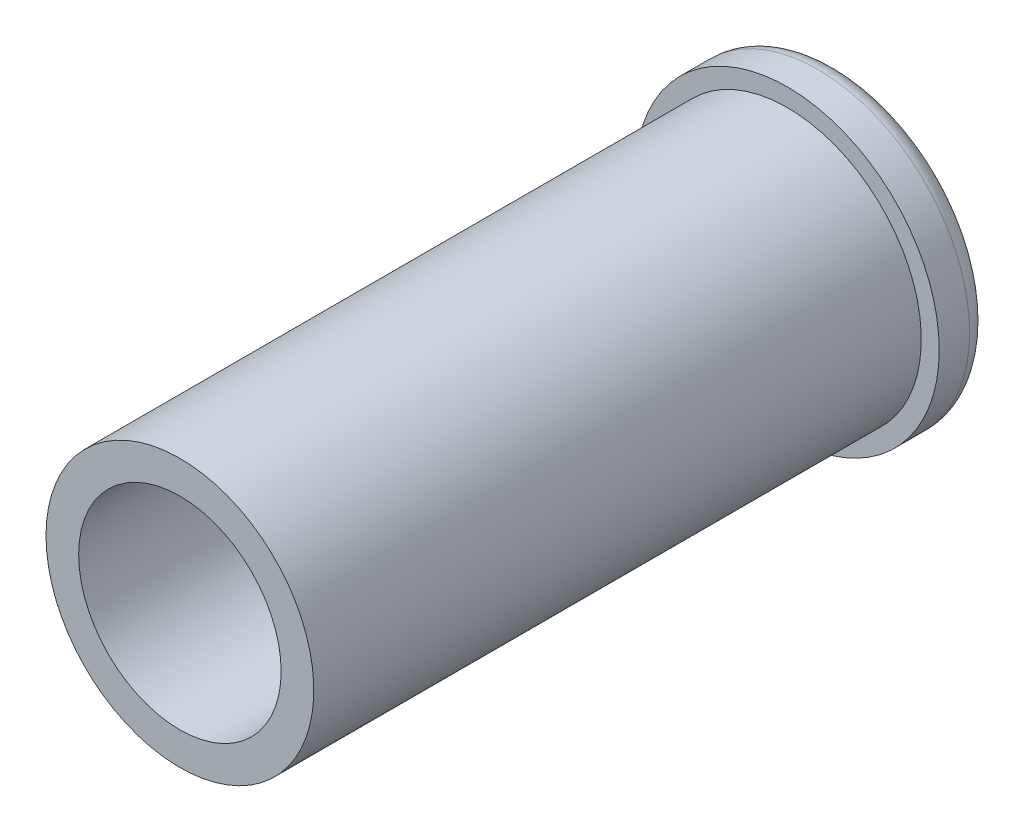
from build123d import *

# Parameters (mm, degrees)
SKETCH2_R               = 8.398
BOSS_EXTRUDE3_DEPTH     = 38.1
SKETCH2_3_R             = 9.525
BOSS_EXTRUDE4_DEPTH     = 3.175
CUT_EXTRUDE1_DEPTH      = 41.411152545
CUT_EXTRUDE1_DEPTH_BACK = 41.411152545
SKETCH3_R               = 6.35
FILLET1_R               = 1.27


with BuildPart() as part:
    # Sketch2 → Boss-Extrude3 (new body)
    with BuildSketch(Plane.XY.offset(25.4)):
        Circle(SKETCH2_R)
    extrude(amount=BOSS_EXTRUDE3_DEPTH)


with BuildPart() as body_2:
    # Sketch2_3 → Boss-Extrude4 (new body)
    with BuildSketch(Plane.XY.offset(25.4)):
        Circle(SKETCH2_3_R)
    extrude(amount=-BOSS_EXTRUDE4_DEPTH)


with BuildPart() as cut_extrude1_tool:
    # Sketch3 → Cut-Extrude1 (new, two sides: drawn at the far end of the back side and taken through both)
    with BuildSketch(Plane.XY.offset(25.4).offset(-CUT_EXTRUDE1_DEPTH_BACK)):
        Circle(SKETCH3_R)
    extrude(amount=CUT_EXTRUDE1_DEPTH + CUT_EXTRUDE1_DEPTH_BACK)


with BuildPart() as part_1:
    add(part.part)

    # Cut-Extrude1: cut by cut_extrude1_tool
    add(cut_extrude1_tool.part, mode=Mode.SUBTRACT)


with BuildPart() as body_2_1:
    add(body_2.part)

    # Cut-Extrude1: cut by cut_extrude1_tool
    add(cut_extrude1_tool.part, mode=Mode.SUBTRACT)

    # Combine1: union part
    add(part_1.part)

    # Fillet1
    fillet1_edges = [body_2_1.edges().sort_by_distance(p)[0] for p in [
        (-9.525, 0, 22.225),
        (-6.35, 0, 22.225),
    ]]
    fillet(fillet1_edges, radius=FILLET1_R)


solid = body_2_1.part
